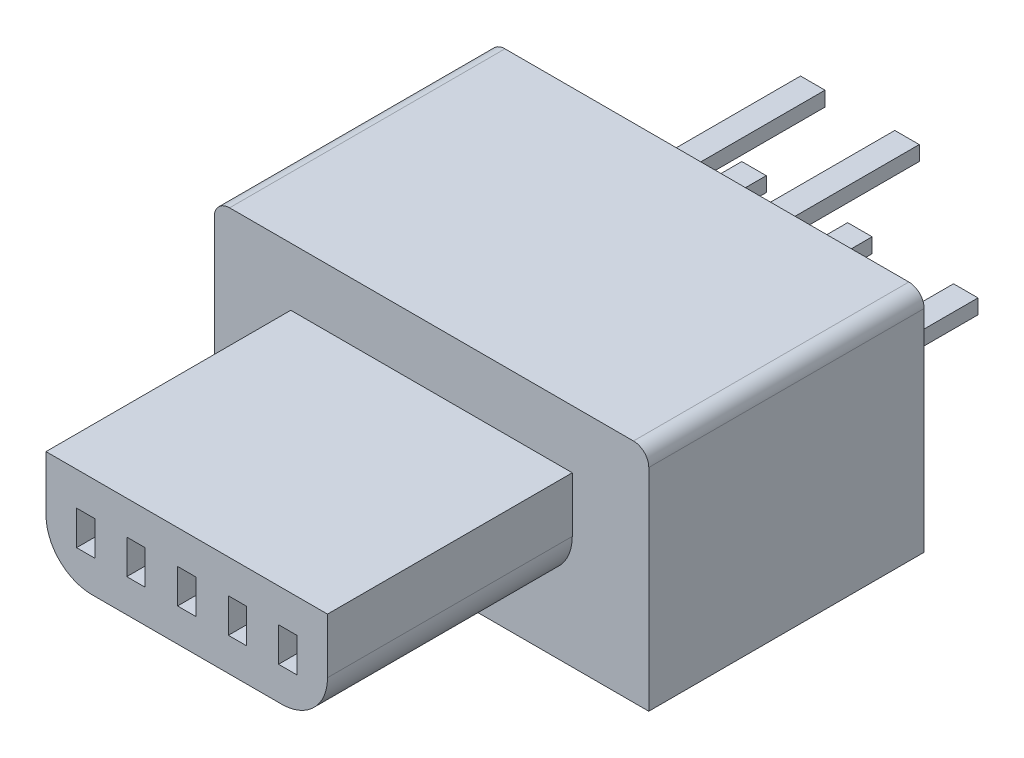
from build123d import *

# Parameters (mm, degrees)
BOSS_EXTRUDE1_START = -0.9
SKETCH2_W           = 0.3
SKETCH2_H           = 0.56
BOSS_EXTRUDE1_DEPTH = 4
BOSS_EXTRUDE2_DEPTH = 4.5
SKETCH4_W           = 0.4
SKETCH4_H           = 0.24
BOSS_EXTRUDE3_DEPTH = 2.5


with BuildPart() as part:
    # Sketch2 → Boss-Extrude1 (new body)
    with BuildSketch(Plane.XY.offset(BOSS_EXTRUDE1_START)):
        with BuildLine():
            Line((2.3, 2.75), (-2.3, 2.75))
            Line((-2.3, 2.75), (-2.3, 1.85))
            ThreePointArc((-2.3, 1.85), (-2.080330086, 1.319669914), (-1.55, 1.1))
            Line((-1.55, 1.1), (1.55, 1.1))
            ThreePointArc((1.55, 1.1), (2.080330086, 1.319669914), (2.3, 1.85))
            Line((2.3, 1.85), (2.3, 2.75))
        make_face()
        with Locations((-1.65, 1.92)):
            Rectangle(SKETCH2_W, SKETCH2_H, mode=Mode.SUBTRACT)
        with Locations((-0.83, 1.92)):
            Rectangle(SKETCH2_W, SKETCH2_H, mode=Mode.SUBTRACT)
        with Locations((0, 1.92)):
            Rectangle(SKETCH2_W, SKETCH2_H, mode=Mode.SUBTRACT)
        with Locations((0.83, 1.92)):
            Rectangle(SKETCH2_W, SKETCH2_H, mode=Mode.SUBTRACT)
        with Locations((1.65, 1.92)):
            Rectangle(SKETCH2_W, SKETCH2_H, mode=Mode.SUBTRACT)
    extrude(amount=-BOSS_EXTRUDE1_DEPTH)

    # Sketch3 → Boss-Extrude2 (add)
    with BuildSketch(Plane(origin=(0, 0, -4.9), x_dir=(-1, 0, 0), z_dir=(0, 0, -1))):
        with BuildLine():
            Line((-3.3, 3.7), (3.3, 3.7))
            ThreePointArc((3.3, 3.7), (3.476776695, 3.626776695), (3.55, 3.45))
            Line((3.55, 3.45), (3.55, 0))
            Line((3.55, 0), (-3.55, 0))
            Line((-3.55, 0), (-3.55, 3.45))
            ThreePointArc((-3.55, 3.45), (-3.476776695, 3.626776695), (-3.3, 3.7))
        make_face()
    extrude(amount=BOSS_EXTRUDE2_DEPTH)

    # Sketch4 → Boss-Extrude3 (add)
    with BuildSketch(Plane(origin=(0, 0, -9.4), x_dir=(-1, 0, 0), z_dir=(0, 0, -1))):
        with Locations((-0.77, 3.11)):
            Rectangle(SKETCH4_W, SKETCH4_H)
        with Locations((0.77, 3.11)):
            Rectangle(SKETCH4_W, SKETCH4_H)
        with Locations((0, 1.42)):
            Rectangle(SKETCH4_W, SKETCH4_H)
        with Locations((1.73, 1.42)):
            Rectangle(SKETCH4_W, SKETCH4_H)
        with Locations((-1.73, 1.42)):
            Rectangle(SKETCH4_W, SKETCH4_H)
    extrude(amount=BOSS_EXTRUDE3_DEPTH)


solid = part.part
